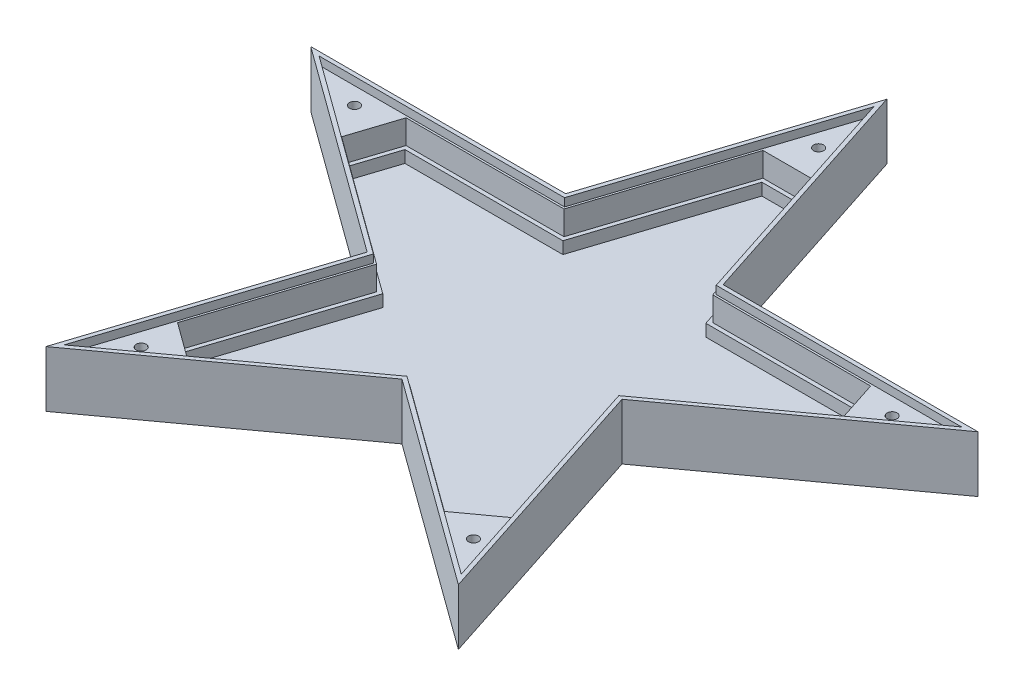
from build123d import *

# Parameters (mm, degrees)
SALIENTE_EXTRUIR1_DEPTH = 14
CORTAR_EXTRUIR1_DEPTH   = 11
CORTAR_EXTRUIR2_DEPTH   = 8
CROQUIS4_OUTSIDE_W      = 214.456
CROQUIS4_OUTSIDE_H      = 206.311
CORTAR_EXTRUIR4_DEPTH   = 2
CROQUIS6_R              = 1.25
CORTAR_EXTRUIR6_DEPTH   = 7


with BuildPart() as part:
    # Croquis1 → Saliente-Extruir1 (new body)
    with BuildSketch(Plane(origin=(0, 0, 0), x_dir=(1, 0, 0), z_dir=(0, 1, 0))):
        Polygon((0, 87.5), (-19.644973975, 27.038987008), (-83.217445176, 27.038987008), (-31.7862356, -10.327974016), (-51.431209576, -70.788987008), (0, -33.422025984), (51.431209576, -70.788987008), (31.7862356, -10.327974016), (83.217445176, 27.038987008), (19.644973975, 27.038987008), align=None)
    extrude(amount=SALIENTE_EXTRUIR1_DEPTH)

    # Croquis2 → Cortar-Extruir1 (cut)
    with BuildSketch(Plane(origin=(0, 14, 0), x_dir=(1, 0, 0), z_dir=(0, 1, 0))):
        Polygon((31.866240983, -53.484035323), (41.019130301, -46.83407198), (28.847309339, -9.373058987), (60.713550322, 13.779120295), (57.217457698, 24.538987008), (17.828617655, 24.538987008), (5.656796693, 62), (-5.656796693, 62), (-17.828617655, 24.538987008), (-57.217457698, 24.538987008), (-60.713550322, 13.779120295), (-28.847309339, -9.373058987), (-41.019130301, -46.83407198), (-31.866240983, -53.484035323), (0, -30.331856041), align=None)
    extrude(amount=-CORTAR_EXTRUIR1_DEPTH, mode=Mode.SUBTRACT)

    # Croquis3 → Cortar-Extruir2 (cut)
    with BuildSketch(Plane(origin=(0, 14, 0), x_dir=(1, 0, 0), z_dir=(0, 1, 0))):
        Polygon((57.944000226, 25.538987008), (18.555160183, 25.538987008), (6.383339221, 63), (-6.383339221, 63), (-18.555160183, 25.538987008), (-57.944000226, 25.538987008), (-61.889120827, 13.397154283), (-30.022879843, -9.755024999), (-42.194700805, -47.216037991), (-31.866240983, -54.7201033), (0, -31.567924018), (31.866240983, -54.7201033), (42.194700805, -47.216037991), (30.022879843, -9.755024999), (61.889120827, 13.397154283), align=None)
        Polygon((57.217457698, 24.538987008), (17.828617655, 24.538987008), (5.656796693, 62), (-5.656796693, 62), (-17.828617655, 24.538987008), (-57.217457698, 24.538987008), (-60.713550322, 13.779120295), (-28.847309339, -9.373058987), (-41.019130301, -46.83407198), (-31.866240983, -53.484035323), (0, -30.331856041), (31.866240983, -53.484035323), (41.019130301, -46.83407198), (28.847309339, -9.373058987), (60.713550322, 13.779120295), align=None, mode=Mode.SUBTRACT)
    extrude(amount=-CORTAR_EXTRUIR2_DEPTH, mode=Mode.SUBTRACT)

    # Croquis4 outside → Cortar-Extruir4 (cut)
    with BuildSketch(Plane(origin=(0, 14, 0), x_dir=(1, 0, 0), z_dir=(0, 1, 0))):
        with Locations((0, 8.3555)):
            Rectangle(CROQUIS4_OUTSIDE_W, CROQUIS4_OUTSIDE_H)
        Polygon((19.644973975, 27.038987008), (0, 87.5), (-19.644973975, 27.038987008), (-83.217445176, 27.038987008), (-31.7862356, -10.327974016), (-51.431209576, -70.788987008), (0, -33.422025984), (51.431209576, -70.788987008), (31.7862356, -10.327974016), (83.217445176, 27.038987008), align=None, mode=Mode.SUBTRACT)
        Polygon((18.918431447, 26.038987008), (0, 84.263932023), (-18.918431447, 26.038987008), (-80.139761639, 26.038987008), (-30.610665096, -9.946008004), (-49.529096543, -68.170953019), (0, -32.185958007), (49.529096543, -68.170953019), (30.610665096, -9.946008004), (80.139761639, 26.038987008), align=None)
    extrude(amount=-CORTAR_EXTRUIR4_DEPTH, mode=Mode.SUBTRACT)

    # Croquis6 → Cortar-Extruir6 (cut)
    with BuildSketch(Plane(origin=(0, 12, 0), x_dir=(1, 0, 0), z_dir=(0, 1, 0))):
        with Locations((-67.049484399, 21.785698103)):
            Circle(CROQUIS6_R)
        with Locations((0, 70.5)):
            Circle(CROQUIS6_R)
        with Locations((67.049484399, 21.785698103)):
            Circle(CROQUIS6_R)
        with Locations((41.438860287, -57.035698103)):
            Circle(CROQUIS6_R)
        with Locations((-41.438860287, -57.035698103)):
            Circle(CROQUIS6_R)
    extrude(amount=-CORTAR_EXTRUIR6_DEPTH, mode=Mode.SUBTRACT)


solid = part.part
